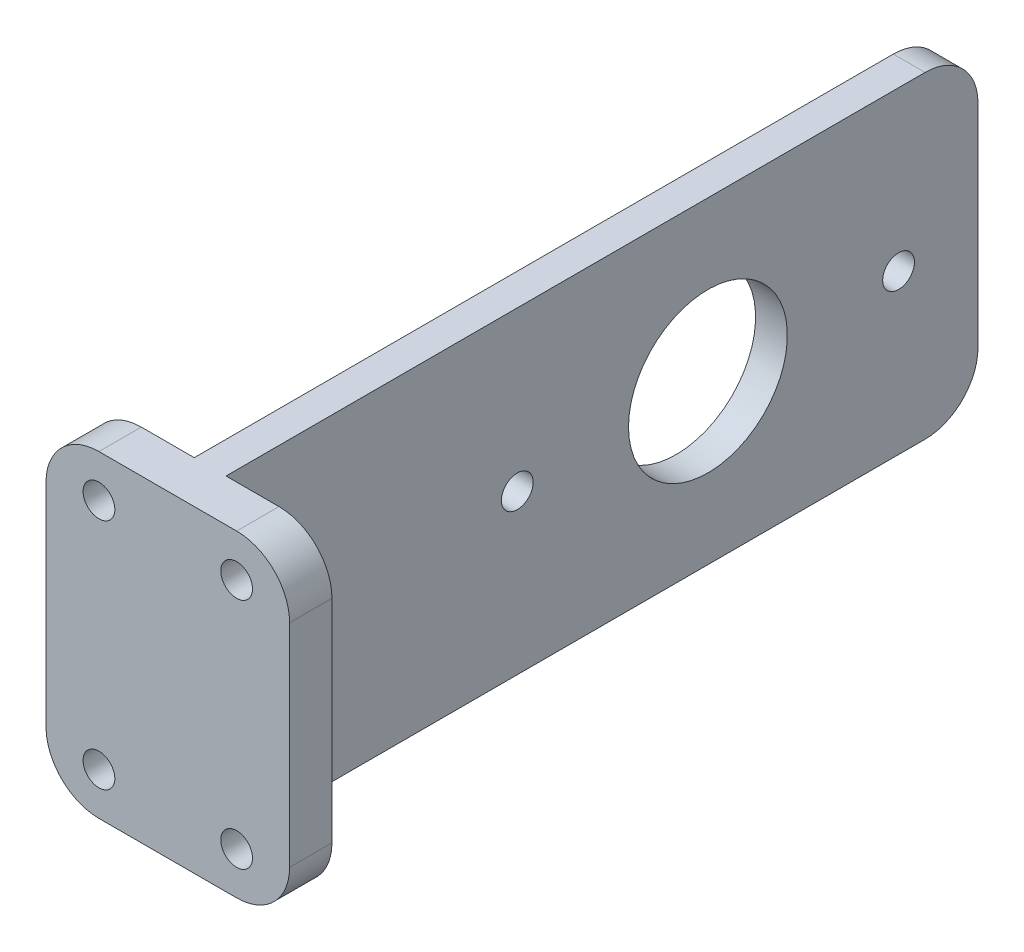
from build123d import *

# Parameters (mm, degrees)
BOSS_EXTRUDE1_DEPTH = 30
SKETCH2_R           = 1.5
SKETCH2_R_2         = 7.5
CUT_EXTRUDE1_DEPTH  = 14
SKETCH3_R           = 1.5
CUT_EXTRUDE2_DEPTH  = 76
FILLET1_R           = 5


with BuildPart() as part:
    # Sketch1 → Boss-Extrude1 (new body)
    with BuildSketch(Plane(origin=(0, 0, 0), x_dir=(1, 0, 0), z_dir=(0, 1, 0))):
        Polygon((-11.5, 4), (-1.5, 4), (-1.5, 75), (1.5, 75), (1.5, 4), (11.5, 4), (11.5, 0), (-11.5, 0), align=None)
    extrude(amount=BOSS_EXTRUDE1_DEPTH)

    # Sketch2 → Cut-Extrude1 (cut, through all)
    with BuildSketch(Plane.ZY.offset(1.5)):
        with Locations((-67.5, 15)):
            Circle(SKETCH2_R)
        with Locations((-31.5, 15)):
            Circle(SKETCH2_R)
        with Locations((-49.5, 15)):
            Circle(SKETCH2_R_2)
    extrude(amount=-CUT_EXTRUDE1_DEPTH, mode=Mode.SUBTRACT)

    # Sketch3 → Cut-Extrude2 (cut, through all)
    with BuildSketch(Plane.XY):
        with Locations((-6.5, 26)):
            Circle(SKETCH3_R)
        with Locations((-6.5, 4)):
            Circle(SKETCH3_R)
        with Locations((6.5, 4)):
            Circle(SKETCH3_R)
        with Locations((6.5, 26)):
            Circle(SKETCH3_R)
    extrude(amount=-CUT_EXTRUDE2_DEPTH, mode=Mode.SUBTRACT)

    # Fillet1
    fillet1_edges = [part.edges().sort_by_distance(p)[0] for p in [
        (11.5, 0, -2),
        (-11.5, 0, -2),
        (11.5, 30, -2),
        (0, 30, -75),
        (-11.5, 30, -2),
        (0, 0, -75),
    ]]
    fillet(fillet1_edges, radius=FILLET1_R)


solid = part.part
